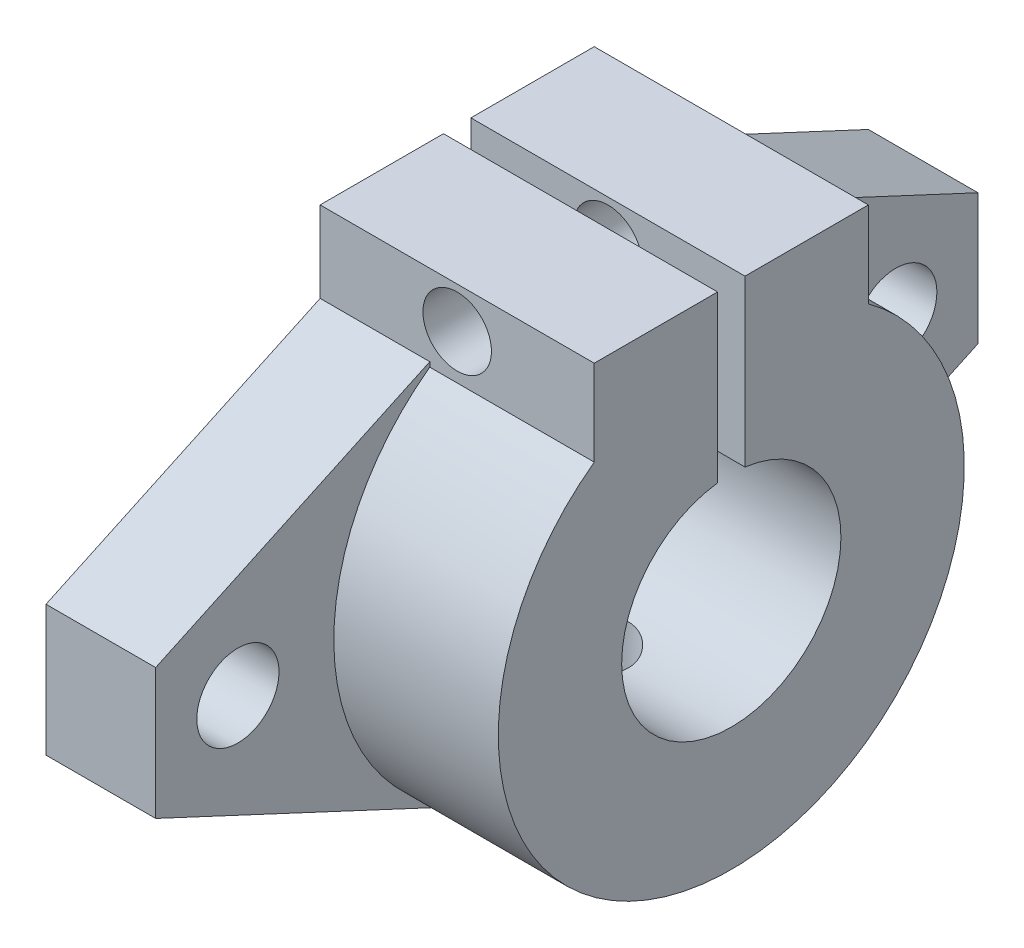
from build123d import *

# Parameters (mm, degrees)
SKETCH_1_R          = 3
EXTRUDE_1_DEPTH     = 8
EXTRUDE_1_2_DEPTH   = 8
SKETCH_1_3_R        = 8
EXTRUDE_2_DEPTH     = 20
EXTRUDE_3_REACH     = 53.662
SKETCH_2_W          = 20
SKETCH_2_H          = 20
SKETCH_3_W          = 20
SKETCH_3_H          = 2
CUT_EXTRUDE_1_DEPTH = 20
SKETCH_4_R          = 2.5
CUT_EXTRUDE_2_DEPTH = 49.989794856
SKETCH_5_R          = 2.5
CUT_EXTRUDE_3_DEPTH = 42.231056256


with BuildPart() as part:
    # 草图1 → 凸台-拉伸1 (new body)
    with BuildSketch(Plane(origin=(0, 0, 0), x_dir=(0, 0, -1), z_dir=(1, 0, 0))):
        with BuildLine():
            Line((-7.18451045, 15.40723238), (-30, 4.768194878))
            Line((-30, 4.768194878), (-30, -4.768194878))
            Line((-30, -4.768194878), (-7.18451045, -15.40723238))
            ThreePointArc((-7.18451045, -15.40723238), (-17, 0), (-7.18451045, 15.40723238))
        make_face()
        with Locations((-24, 0)):
            Circle(SKETCH_1_R, mode=Mode.SUBTRACT)
    extrude(amount=EXTRUDE_1_DEPTH)



with BuildPart() as body_2:
    # 草图1 → Extrude 1 2 (new body)
    with BuildSketch(Plane(origin=(0, 0, 0), x_dir=(0, 0, -1), z_dir=(1, 0, 0))):
        with BuildLine():
            Line((30, 4.768194878), (7.18451045, 15.40723238))
            ThreePointArc((7.18451045, 15.40723238), (17, 0), (7.18451045, -15.40723238))
            Line((7.18451045, -15.40723238), (30, -4.768194878))
            Line((30, -4.768194878), (30, 4.768194878))
        make_face()
        with Locations((24, 0)):
            Circle(SKETCH_1_R, mode=Mode.SUBTRACT)
    extrude(amount=EXTRUDE_1_2_DEPTH)


with BuildPart() as part_1:
    add(part.part)

    add(body_2.part)  # 凸台-拉伸2 merges body 2
    # 草图1<3> → 凸台-拉伸2 (add)
    with BuildSketch(Plane(origin=(0, 0, 0), x_dir=(0, 0, -1), z_dir=(1, 0, 0))):
        with BuildLine():
            ThreePointArc((7.18451045, 15.40723238), (0, 17), (-7.18451045, 15.40723238))
            ThreePointArc((-7.18451045, 15.40723238), (-17, 0), (-7.18451045, -15.40723238))
            ThreePointArc((-7.18451045, -15.40723238), (0, -17), (7.18451045, -15.40723238))
            ThreePointArc((7.18451045, -15.40723238), (14.337654579, -9.134093342), (17, 0))
            ThreePointArc((17, 0), (14.337654579, 9.134093342), (7.18451045, 15.40723238))
        make_face()
        Circle(SKETCH_1_3_R, mode=Mode.SUBTRACT)
    extrude(amount=EXTRUDE_2_DEPTH)

    # 草图2 → 凸台-拉伸3 (add, up to next)
    with BuildSketch(Plane(origin=(0, 20, 0), x_dir=(1, 0, 0), z_dir=(0, 1, 0)), mode=Mode.PRIVATE) as extrude_3_sk1:
        with Locations((10, 0)):
            Rectangle(SKETCH_2_W, SKETCH_2_H)
    extrude_3_tool1 = extrude(extrude_3_sk1.sketch, amount=-EXTRUDE_3_REACH, mode=Mode.PRIVATE) - part_1.part
    add(extrude_3_tool1.solids().sort_by_distance((10, 20, 0))[0])

    # 草图3 → 切除-拉伸1 (cut)
    with BuildSketch(Plane(origin=(0, 20, 0), x_dir=(1, 0, 0), z_dir=(0, 1, 0))):
        with Locations((10, 0)):
            Rectangle(SKETCH_3_W, SKETCH_3_H)
    extrude(amount=-CUT_EXTRUDE_1_DEPTH, mode=Mode.SUBTRACT)

    # 草图4 → 切除-拉伸2 (cut, through all)
    with BuildSketch(Plane.XY.offset(10)):
        with Locations((10, 17)):
            Circle(SKETCH_4_R)
    extrude(amount=-CUT_EXTRUDE_2_DEPTH, mode=Mode.SUBTRACT)

    # 草图5 → 切除-拉伸3 (cut, through all)
    with BuildSketch(Plane(origin=(0, 0, 0), x_dir=(1, 0, 0), z_dir=(0, 1, 0))):
        with Locations((10, 0)):
            Circle(SKETCH_5_R)
    extrude(amount=-CUT_EXTRUDE_3_DEPTH, mode=Mode.SUBTRACT)


solid = part_1.part
